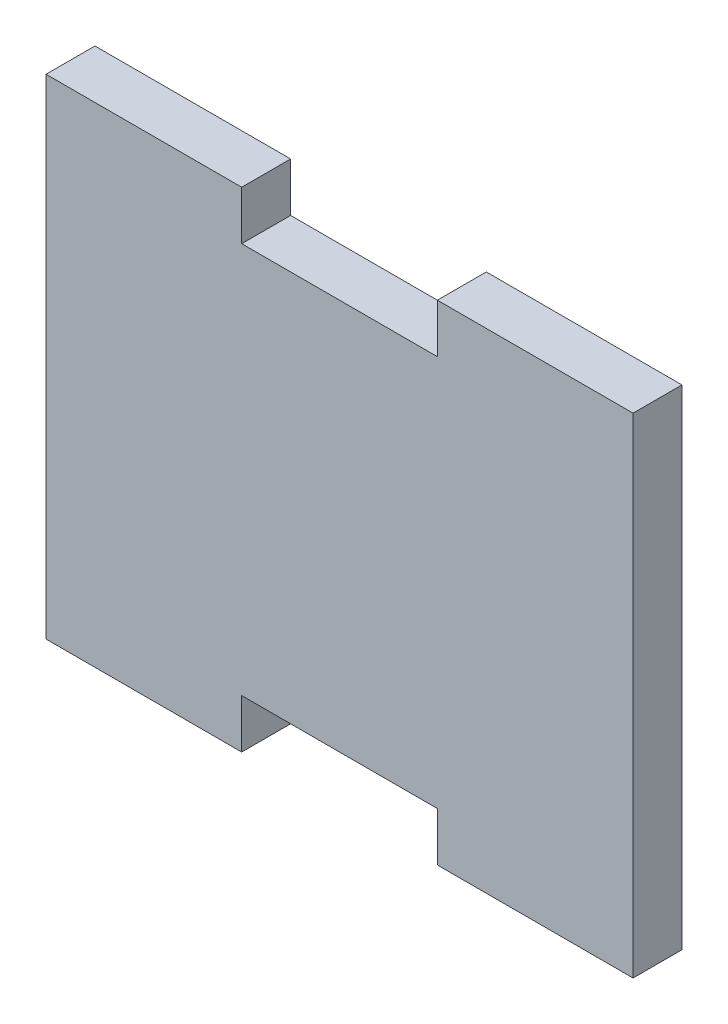
from build123d import *

# Parameters (mm, degrees)
SKETCH1_W           = 60
SKETCH1_H           = 40
SKETCH1_W_2         = 20
SKETCH1_H_2         = 5
BOSS_EXTRUDE1_DEPTH = 5


with BuildPart() as part:
    # Sketch1 → Boss-Extrude1 (new body)
    with BuildSketch(Plane.XY):
        Rectangle(SKETCH1_W, SKETCH1_H)
        with Locations((-20, 22.5)):
            Rectangle(SKETCH1_W_2, SKETCH1_H_2)
        with Locations((20, -22.5)):
            Rectangle(SKETCH1_W_2, SKETCH1_H_2)
        with Locations((-20, -22.5)):
            Rectangle(SKETCH1_W_2, SKETCH1_H_2)
        with Locations((20, 22.5)):
            Rectangle(SKETCH1_W_2, SKETCH1_H_2)
    extrude(amount=BOSS_EXTRUDE1_DEPTH)


solid = part.part
